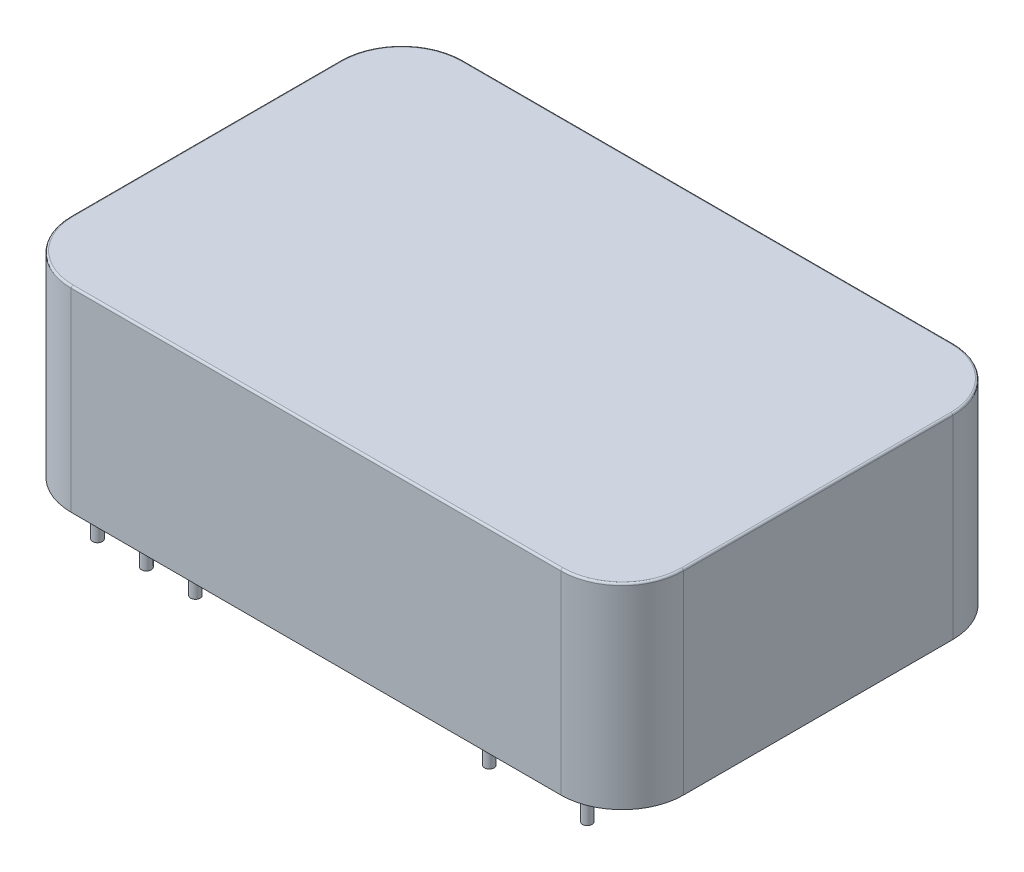
from build123d import *

# Parameters (mm, degrees)
SKETCH1_W           = 31.75
SKETCH1_H           = 20.32
BOSS_EXTRUDE1_DEPTH = 10.16
SKETCH2_R           = 0.25
BOSS_EXTRUDE2_DEPTH = 3.05
FILLET1_R           = 3.18
FILLET2_R           = 0.1


with BuildPart() as part:
    # Sketch1 → Boss-Extrude1 (new body)
    with BuildSketch(Plane(origin=(0, 0, 0), x_dir=(1, 0, 0), z_dir=(0, 1, 0))):
        Rectangle(SKETCH1_W, SKETCH1_H)
    extrude(amount=BOSS_EXTRUDE1_DEPTH)

    # Sketch2 → Boss-Extrude2 (add)
    with BuildSketch(Plane.XZ):
        with Locations((-13.875, 7.62)):
            Circle(SKETCH2_R)
        with Locations((-11.335, 7.62)):
            Circle(SKETCH2_R)
        with Locations((-8.795, 7.62)):
            Circle(SKETCH2_R)
        with Locations((6.445, 7.62)):
            Circle(SKETCH2_R)
        with Locations((11.525, 7.62)):
            Circle(SKETCH2_R)
        with Locations((11.525, -7.62)):
            Circle(SKETCH2_R)
        with Locations((6.445, -7.62)):
            Circle(SKETCH2_R)
        with Locations((-8.795, -7.62)):
            Circle(SKETCH2_R)
        with Locations((-11.335, -7.62)):
            Circle(SKETCH2_R)
    extrude(amount=BOSS_EXTRUDE2_DEPTH)

    # Fillet1
    fillet1_edges = [part.edges().sort_by_distance(p)[0] for p in [
        (-15.875, 5.08, -10.16),
        (15.875, 5.08, -10.16),
        (15.875, 5.08, 10.16),
        (-15.875, 5.08, 10.16),
    ]]
    fillet(fillet1_edges, radius=FILLET1_R)

    # Fillet2
    fillet2_edges = [part.edges().sort_by_distance(p)[0] for p in [
        (0, 10.16, -10.16),
        (15.875, 10.16, 0),
        (-15.875, 10.16, 0),
        (0, 10.16, 10.16),
        (-14.943599564, 10.16, 9.228599564),
        (-14.943599564, 10.16, -9.228599564),
        (14.943599564, 10.16, 9.228599564),
        (14.943599564, 10.16, -9.228599564),
    ]]
    fillet(fillet2_edges, radius=FILLET2_R)


solid = part.part
